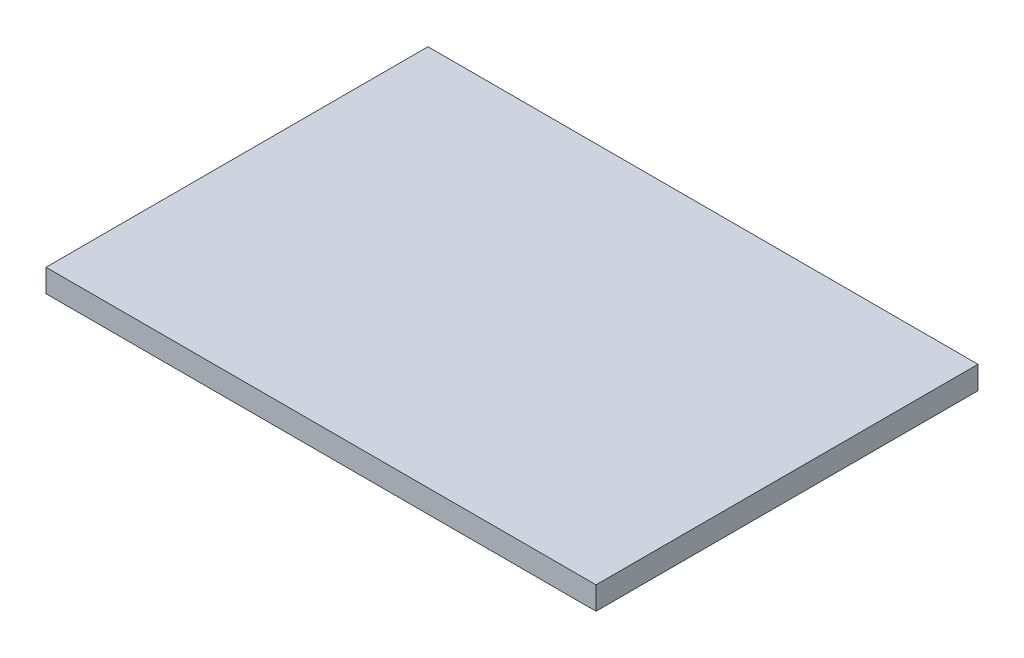
from build123d import *

# Parameters (mm, degrees)
SKETCH_1_W      = 72
SKETCH_1_H      = 50
EXTRUDE_1_DEPTH = 3


with BuildPart() as part:
    # 草图1 → 凸台-拉伸1 (new body)
    with BuildSketch(Plane(origin=(0, 0, 0), x_dir=(1, 0, 0), z_dir=(0, 1, 0))):
        Rectangle(SKETCH_1_W, SKETCH_1_H)
    extrude(amount=EXTRUDE_1_DEPTH)


solid = part.part
